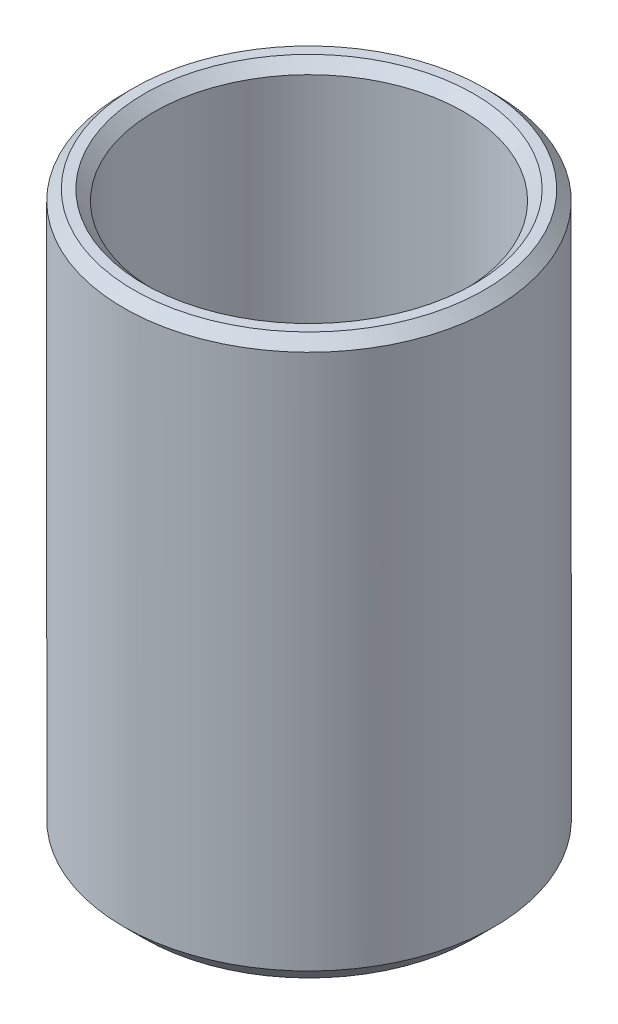
from build123d import *

# Parameters (mm, degrees)
CHAMFER_1_SIZE = 2
CHAMFER_2_SIZE = 1
CHAMFER_3_SIZE = 1


with BuildPart() as part:
    # Эскиз1 → Повернуть1 (revolve)
    with BuildSketch(Plane.XY):
        Polygon((0, 0), (-18, 0), (-18, 55), (-15, 55), (-15, 3), (0, 3), align=None)
    revolve(axis=Axis((0, 3, 0), (0, 1, 0)))

    # Фаска1
    chamfer_1_edges = [part.edges().sort_by_distance(p)[0] for p in [
        (18, 0, 0),
    ]]
    chamfer(chamfer_1_edges, length=CHAMFER_1_SIZE)

    # Фаска2
    chamfer_2_edges = [part.edges().sort_by_distance(p)[0] for p in [
        (15, 55, 0),
        (18, 55, 0),
    ]]
    chamfer(chamfer_2_edges, length=CHAMFER_2_SIZE)

    # Фаска3
    chamfer_3_edges = [part.edges().sort_by_distance(p)[0] for p in [
        (15, 3, 0),
    ]]
    chamfer(chamfer_3_edges, length=CHAMFER_3_SIZE)


solid = part.part
